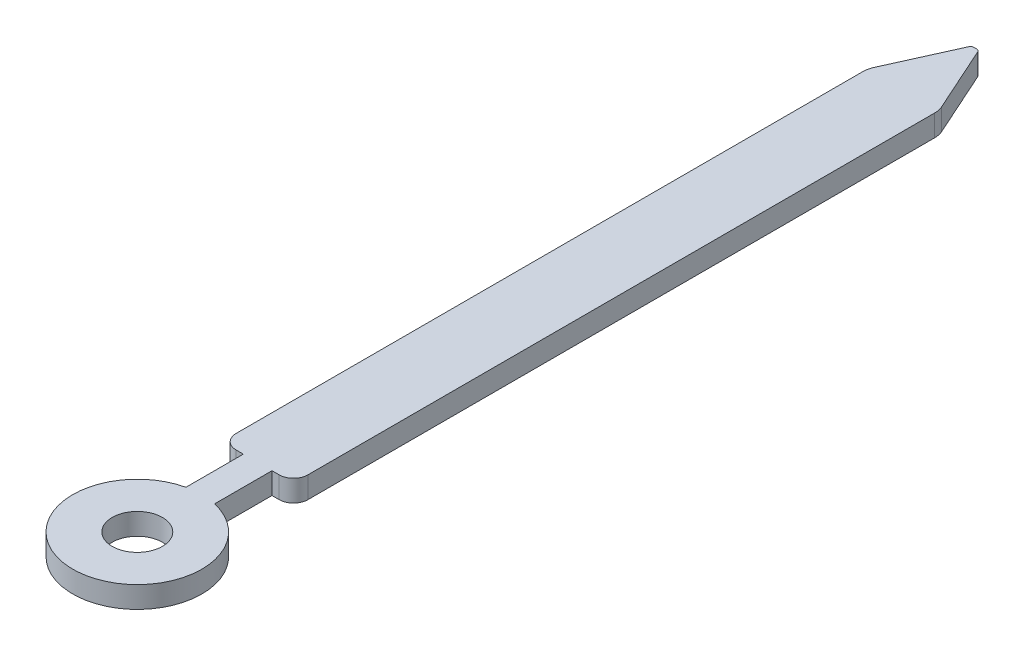
from build123d import *

# Parameters (mm, degrees)
SKETCH1_R           = 0.35
BOSS_EXTRUDE1_DEPTH = 0.3


with BuildPart() as part:
    # Sketch1 → Boss-Extrude1 (new body)
    with BuildSketch(Plane(origin=(0, 0, 0), x_dir=(1, 0, 0), z_dir=(0, 1, 0))):
        with BuildLine():
            Line((0.063001459, 9.971107869), (0.473576452, 9.058718997))
            ThreePointArc((0.473576452, 9.058718997), (0.493319736, 8.998566184), (0.5, 8.935609593))
            Line((0.5, 8.935609593), (0.5, 0.2))
            ThreePointArc((0.5, 0.2), (0.441421356, 0.058578644), (0.3, 0))
            Line((0.3, 0), (0.2, 0))
            Line((0.2, 0), (0.2, -0.8))
            ThreePointArc((0.2, -0.8), (0, -2.577496439), (-0.2, -0.8))
            Line((-0.2, -0.8), (-0.2, 0))
            Line((-0.2, 0), (-0.3, 0))
            ThreePointArc((-0.3, 0), (-0.441421356, 0.058578644), (-0.5, 0.2))
            Line((-0.5, 0.2), (-0.5, 8.935609593))
            ThreePointArc((-0.5, 8.935609593), (-0.493319736, 8.998566184), (-0.473576452, 9.058718997))
            Line((-0.473576452, 9.058718997), (-0.063001459, 9.971107869))
            ThreePointArc((-0.063001459, 9.971107869), (-0.044922891, 9.992147816), (-0.018317305, 10))
            Line((-0.018317305, 10), (0.018317305, 10))
            ThreePointArc((0.018317305, 10), (0.044922891, 9.992147816), (0.063001459, 9.971107869))
        make_face()
        with Locations((0, -1.677496439)):
            Circle(SKETCH1_R, mode=Mode.SUBTRACT)
    extrude(amount=BOSS_EXTRUDE1_DEPTH)


solid = part.part
